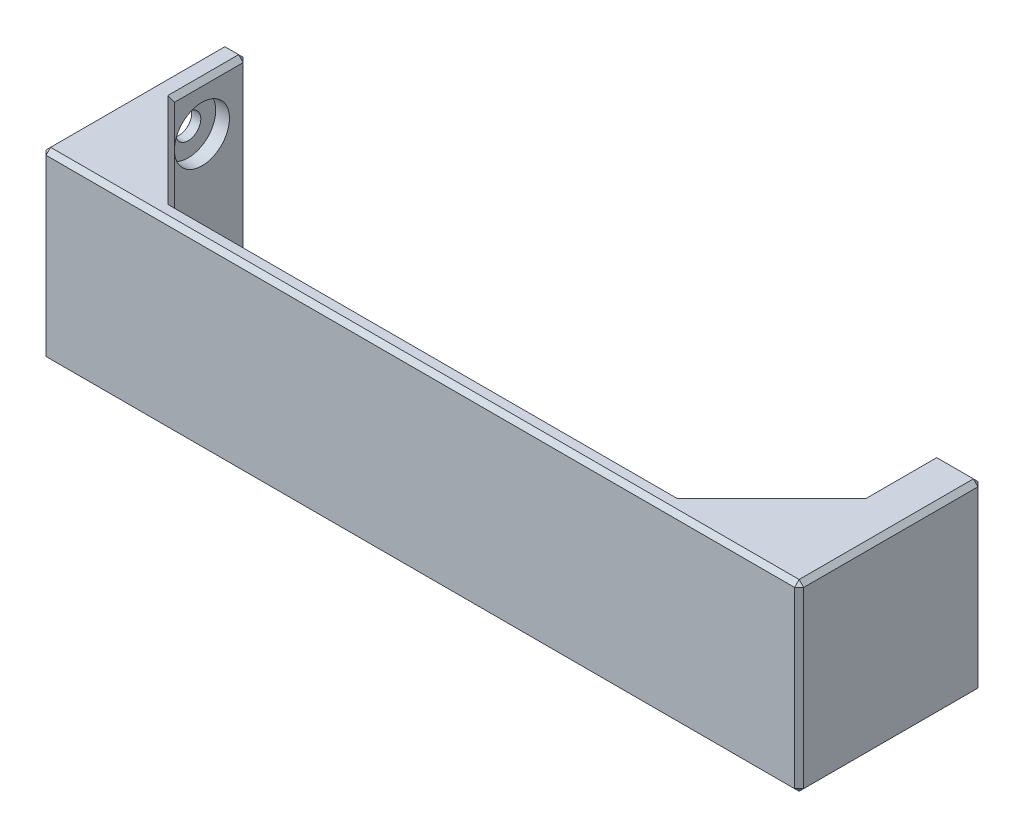
from build123d import *

# Parameters (mm, degrees)
BOSS_EXTRUDE1_DEPTH                     = 40
SKETCH2_W                               = 40
SKETCH2_H                               = 40
BOSS_EXTRUDE2_DEPTH                     = 5
SKETCH3_W                               = 40
SKETCH3_H                               = 40
BOSS_EXTRUDE3_DEPTH                     = 10
CUT_EXTRUDE1_DEPTH                      = 30
CUT_EXTRUDE2_DEPTH                      = 30
CBORE_FOR_M5_HEX_HEAD_BOLT1_D           = 5.5
CBORE_FOR_M5_HEX_HEAD_BOLT1_DEPTH       = 5
CBORE_FOR_M5_HEX_HEAD_BOLT1_CBORE_D     = 12
CBORE_FOR_M5_HEX_HEAD_BOLT1_CBORE_DEPTH = 3
CHAMFER1_SIZE                           = 1


with BuildPart() as part:
    # Sketch1 → Boss-Extrude1 (new body)
    with BuildSketch(Plane(origin=(0, 20, 0), x_dir=(1, 0, 0), z_dir=(0, 1, 0))):
        Polygon((5, 4), (5, -20), (155.2, -20), (155.2, 4), (135.2, -16), (25, -16), align=None)
    extrude(amount=-BOSS_EXTRUDE1_DEPTH)

    # Sketch2 → Boss-Extrude2 (add)
    with BuildSketch(Plane.ZY.offset(-5)):
        Rectangle(SKETCH2_W, SKETCH2_H)
    extrude(amount=BOSS_EXTRUDE2_DEPTH)

    # Sketch3 → Boss-Extrude3 (add)
    with BuildSketch(Plane(origin=(155.2, 0, 0), x_dir=(0, 0, -1), z_dir=(1, 0, 0))):
        Rectangle(SKETCH3_W, SKETCH3_H)
    extrude(amount=BOSS_EXTRUDE3_DEPTH)

    # Sketch4 → Cut-Extrude1 (cut)
    with BuildSketch(Plane.XZ.offset(15)):
        Polygon((155.2, -4), (155.2, 16), (135.2, 16), align=None)
    extrude(amount=-CUT_EXTRUDE1_DEPTH, mode=Mode.SUBTRACT)

    # Sketch5 → Cut-Extrude2 (cut)
    with BuildSketch(Plane(origin=(0, 15, 0), x_dir=(1, 0, 0), z_dir=(0, 1, 0))):
        Polygon((5, 4), (5, -16), (25, -16), align=None)
    extrude(amount=-CUT_EXTRUDE2_DEPTH, mode=Mode.SUBTRACT)

    # Sketch6 → CBORE for M10 Hex Head Bolt1 (revolve, cut)
    with BuildSketch(Plane(origin=(0, -10, 10), x_dir=(0, 0, 1), z_dir=(0, 1, 0))):
        Polygon((0, 0), (0, 5), (6, 5), (6, 2), (2.75, 2), (2.75, 0), align=None)
    revolve(axis=Axis((-6.35, -10, 10), (1, 0, 0)), mode=Mode.SUBTRACT)

    # CBORE for M5 Hex Head Bolt1
    with Locations(Plane(origin=(5, 0, 0), x_dir=(0, 0, -1), z_dir=(1, 0, 0))):
        with Locations((10, 10)):
            CounterBoreHole(CBORE_FOR_M5_HEX_HEAD_BOLT1_D / 2, CBORE_FOR_M5_HEX_HEAD_BOLT1_CBORE_D / 2, CBORE_FOR_M5_HEX_HEAD_BOLT1_CBORE_DEPTH, depth=CBORE_FOR_M5_HEX_HEAD_BOLT1_DEPTH)

    # Chamfer1
    chamfer1_edges = [part.edges().sort_by_distance(p)[0] for p in [
        (82.6, -20, 20),
        (5, 20, -12),
        (5, 0, -20),
        (2.5, 20, -20),
        (5, -20, -12),
        (145.2, -20, 6),
        (2.5, -20, -20),
        (0, 20, 0),
        (0, -20, 0),
        (0, 0, 20),
        (80.1, -20, 16),
        (155.2, 20, -12),
        (160.2, 20, -20),
        (155.2, -20, -12),
        (155.2, 0, -20),
        (160.2, -20, -20),
        (165.2, 20, 0),
        (165.2, 0, 20),
        (165.2, -20, 0),
        (165.2, 0, -20),
        (145.2, 15, 6),
        (145.2, -15, 6),
        (15, -20, 6),
        (15, -15, 6),
        (15, 15, 6),
        (80.1, 20, 16),
        (145.2, 20, 6),
        (82.6, 20, 20),
        (15, 20, 6),
    ]]
    chamfer(chamfer1_edges, length=CHAMFER1_SIZE)


solid = part.part
